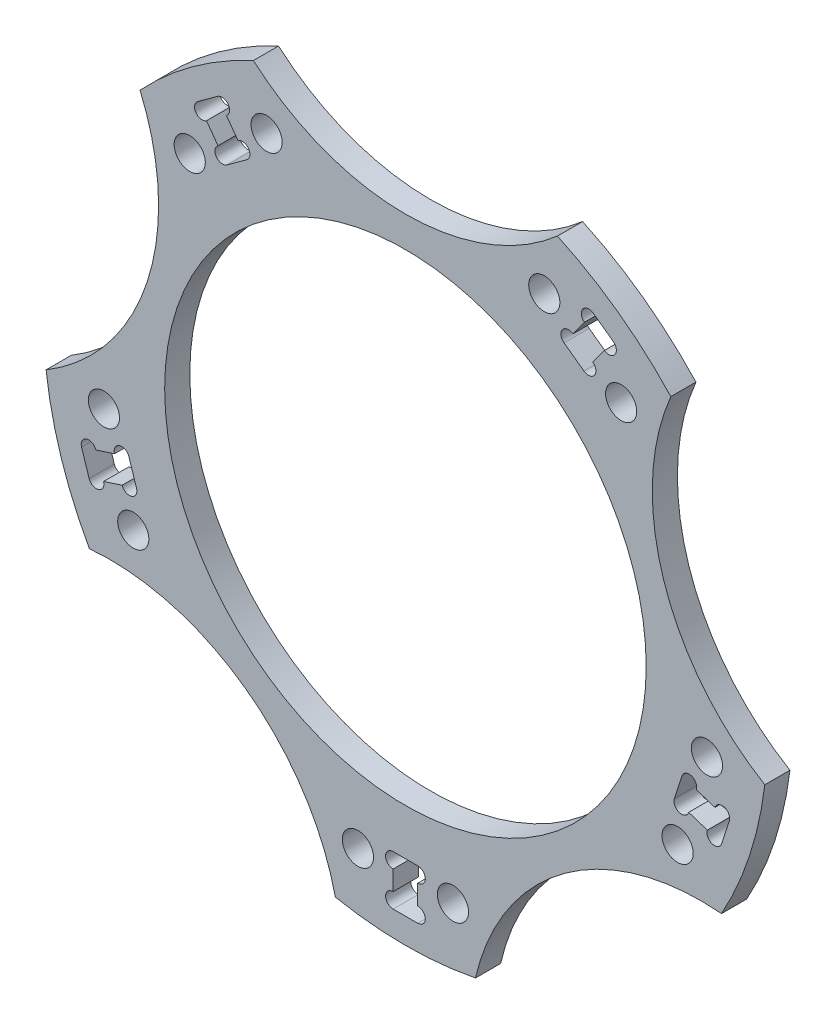
from build123d import *

# Parameters (mm, degrees)
SKETCH_1_R               = 23.95
EXTRUDE_1_DEPTH          = 1.25
SKETCH_2_W               = 2.45
SKETCH_2_H               = 4.95
CUT_EXTRUDE_1_DEPTH      = 3.5
SKETCH_3_R               = 0.75
CUT_EXTRUDE_2_DEPTH      = 3.5
SKETCH_4_R               = 1.55
CUT_EXTRUDE_3_DEPTH      = 3.5
PATTERN_CIRCULAR_1_COUNT = 5


with BuildPart() as part:
    # 草图1 → 凸台-拉伸1 (new body, symmetric)
    with BuildSketch(Plane.XY):
        with BuildLine():
            ThreePointArc((-15.121874884, 32.67), (-21.160269083, 29.124611797), (-26.398100061, 24.477342853))
            ThreePointArc((-26.398100061, 24.477342853), (-25.67852594, 8.343458848), (-35.743932713, -4.286172441))
            ThreePointArc((-35.743932713, -4.286172441), (-34.238034587, -11.124611797), (-31.43679796, -17.542170163))
            ThreePointArc((-31.43679796, -17.542170163), (-15.870201812, -21.843458848), (-6.969090425, -35.31900025))
            ThreePointArc((-6.969090425, -35.31900025), (0, -36), (6.969090425, -35.31900025))
            ThreePointArc((6.969090425, -35.31900025), (15.870201812, -21.843458848), (31.43679796, -17.542170163))
            ThreePointArc((31.43679796, -17.542170163), (34.238034587, -11.124611797), (35.743932713, -4.286172441))
            ThreePointArc((35.743932713, -4.286172441), (25.67852594, 8.343458848), (26.398100061, 24.477342853))
            ThreePointArc((26.398100061, 24.477342853), (21.160269083, 29.124611797), (15.121874884, 32.67))
            ThreePointArc((15.121874884, 32.67), (0, 27), (-15.121874884, 32.67))
        make_face()
        Circle(SKETCH_1_R, mode=Mode.SUBTRACT)
    extrude(amount=EXTRUDE_1_DEPTH, both=True)

    # 草图2 → 切除-拉伸1 (cut, through all)
    with BuildSketch(Plane.XY.offset(1.25)):
        with Locations((0, -31)):
            Rectangle(SKETCH_2_W, SKETCH_2_H)
    cut_extrude_1 = extrude(amount=-CUT_EXTRUDE_1_DEPTH, mode=Mode.SUBTRACT)

    # 草图3 → 切除-拉伸2 (cut, through all)
    with BuildSketch(Plane.XY.offset(1.25)):
        with Locations((-1.225, -29.275)):
            Circle(SKETCH_3_R)
        with Locations((1.225, -29.275)):
            Circle(SKETCH_3_R)
        with Locations((-1.225, -32.725)):
            Circle(SKETCH_3_R)
        with Locations((1.225, -32.725)):
            Circle(SKETCH_3_R)
    cut_extrude_2 = extrude(amount=-CUT_EXTRUDE_2_DEPTH, mode=Mode.SUBTRACT)

    # 草图4 → 切除-拉伸3 (cut, through all)
    with BuildSketch(Plane.XY.offset(1.25)):
        with Locations((-4.725, -30)):
            Circle(SKETCH_4_R)
        with Locations((4.725, -30)):
            Circle(SKETCH_4_R)
    cut_extrude_3 = extrude(amount=-CUT_EXTRUDE_3_DEPTH, mode=Mode.SUBTRACT)

    # 阵列(圆周)1: 切除-拉伸1, 切除-拉伸2, 切除-拉伸3 ×5 about axis
    pattern_circular_1_axis = Axis((0, 0, 0), (0, 0, 1))
    for i in range(1, PATTERN_CIRCULAR_1_COUNT):
        add(cut_extrude_1.rotate(pattern_circular_1_axis, i * 360 / PATTERN_CIRCULAR_1_COUNT), mode=Mode.SUBTRACT)
        add(cut_extrude_2.rotate(pattern_circular_1_axis, i * 360 / PATTERN_CIRCULAR_1_COUNT), mode=Mode.SUBTRACT)
        add(cut_extrude_3.rotate(pattern_circular_1_axis, i * 360 / PATTERN_CIRCULAR_1_COUNT), mode=Mode.SUBTRACT)


solid = part.part
